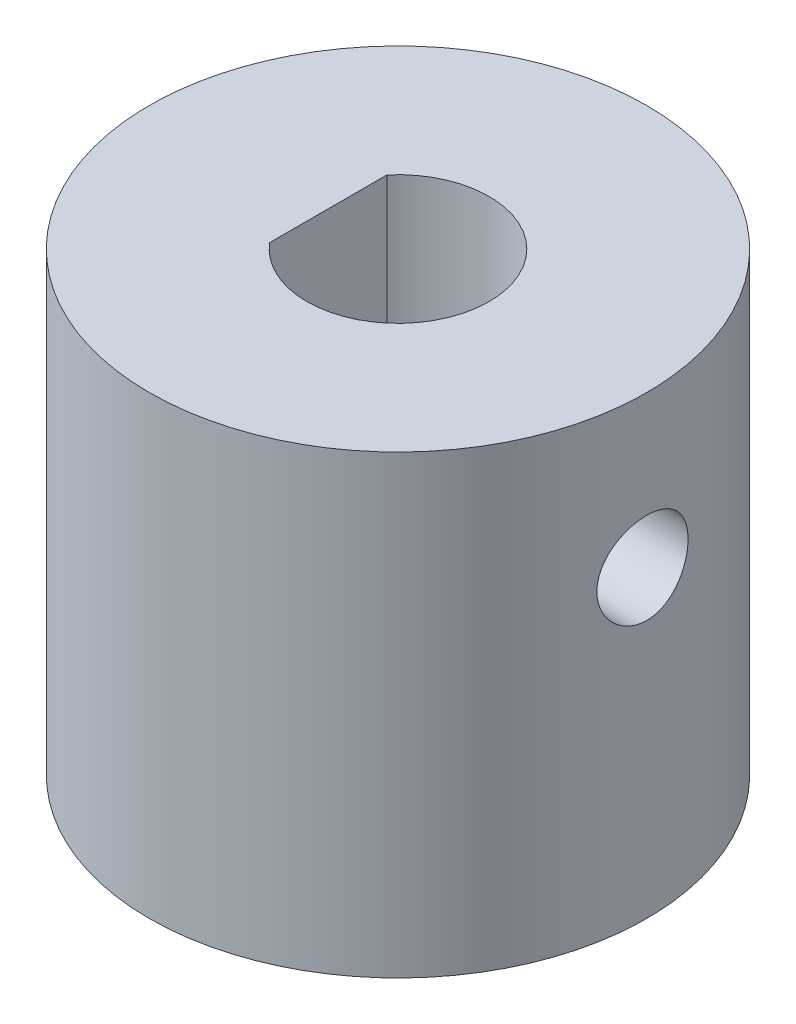
from build123d import *

# Parameters (mm, degrees)
SKETCH1_R               = 8.189006913
BOSS_EXTRUDE1_DEPTH     = 15
SKETCH2_R               = 3
CUT_EXTRUDE1_DEPTH      = 30
SKETCH4_W               = 1.839212521
SKETCH4_H               = 4.190652527
BOSS_EXTRUDE2_DEPTH     = 10
CUT_EXTRUDE2_DEPTH      = 10
CUT_EXTRUDE2_DEPTH_BACK = 10
SKETCH3_R               = 1.5


with BuildPart() as part:
    # Sketch1 → Boss-Extrude1 (new body)
    with BuildSketch(Plane(origin=(0, 0, 0), x_dir=(1, 0, 0), z_dir=(0, 1, 0))):
        Circle(SKETCH1_R)
    extrude(amount=BOSS_EXTRUDE1_DEPTH)

    # Sketch2 → Cut-Extrude1 (cut)
    with BuildSketch(Plane(origin=(0, 15, 0), x_dir=(1, 0, 0), z_dir=(0, 1, 0))):
        Circle(SKETCH2_R)
    extrude(amount=-CUT_EXTRUDE1_DEPTH, mode=Mode.SUBTRACT)

    # Sketch4 → Boss-Extrude2 (add)
    with BuildSketch(Plane(origin=(0, 15, 0), x_dir=(1, 0, 0), z_dir=(0, 1, 0))):
        with Locations((-3.214713917, 0.163363311)):
            Rectangle(SKETCH4_W, SKETCH4_H)
    extrude(amount=-BOSS_EXTRUDE2_DEPTH)

    # Sketch3 → Cut-Extrude2 (cut, two sides: drawn at the far end of the back side and taken through both)
    with BuildSketch(Plane(origin=(0, 0, 0), x_dir=(0, 0, -1), z_dir=(1, 0, 0)).offset(-CUT_EXTRUDE2_DEPTH_BACK)):
        with Locations((0, 10)):
            Circle(SKETCH3_R)
    extrude(amount=CUT_EXTRUDE2_DEPTH + CUT_EXTRUDE2_DEPTH_BACK, mode=Mode.SUBTRACT)


solid = part.part
